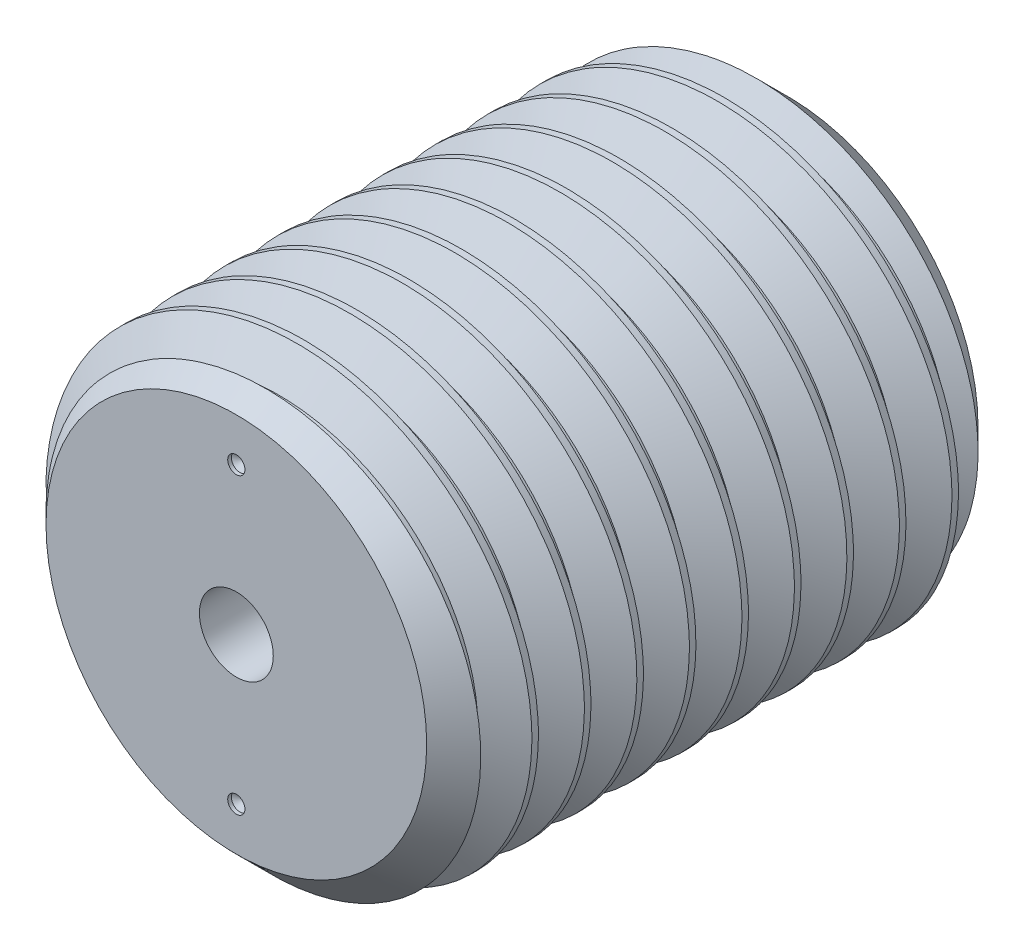
from build123d import *

# Parameters (mm, degrees)
SKETCH1_R                           = 15.875
BOSS_EXTRUDE1_DEPTH                 = 19.05
CHAMFER1_SIZE                       = 2.721428571
CUT_SWEEP1_PITCH                    = 3.628571429
CUT_SWEEP1_HEIGHT                   = 41.728571429
CUT_SWEEP1_RADIUS                   = 15.875
CUT_SWEEP1_START_ANGLE              = 90
F_1_4_20_TAPPED_HOLE1_D             = 5.1054
F_1_4_20_TAPPED_HOLE1_DEPTH         = 11.938
F_1_4_20_TAPPED_HOLE1_TIP           = 1.533816902
F_3_64_0_04688_DIAMETER_HOLE1_D     = 1.190752
F_3_64_0_04688_DIAMETER_HOLE1_DEPTH = 0.254
F_3_64_0_04688_DIAMETER_HOLE1_TIP   = 0.357737992


with BuildPart() as part:
    # Sketch1 → Boss-Extrude1 (new, symmetric)
    with BuildSketch(Plane.XY):
        with Locations(Location((0, 0, 0), (0, 0, 180))):
            Circle(SKETCH1_R)
    extrude(amount=BOSS_EXTRUDE1_DEPTH, both=True)

    # Chamfer1
    chamfer1_edges = [part.edges().sort_by_distance(p)[0] for p in [
        (15.875, 0, -19.05),
        (15.875, 0, 19.05),
    ]]
    chamfer(chamfer1_edges, length=CHAMFER1_SIZE)

    # Cut-Sweep1: sweep along a helix
    with BuildLine() as cut_sweep1_path:
        add(Helix(CUT_SWEEP1_PITCH, CUT_SWEEP1_HEIGHT, CUT_SWEEP1_RADIUS, center=(0, 0, 19.05), direction=(0, 0, -1), mode=Mode.PRIVATE).rotate(Axis((0, 0, 19.05), (0, 0, -1)), CUT_SWEEP1_START_ANGLE))
    # Sketch5 → Cut-Sweep1 (sweep, cut)
    with BuildSketch(Plane(origin=(0, 0, 0), x_dir=(0, 0, -1), z_dir=(1, 0, 0))):
        Polygon((-20.864285714, 13.518173723), (-20.410714286, 13.518173723), (-18.903353032, 16.129), (-22.371646968, 16.129), align=None)
    sweep(path=cut_sweep1_path.line, is_frenet=True, mode=Mode.SUBTRACT)

    # 1/4-20 Tapped Hole1
    with Locations(Plane.XY.offset(19.05)):
        with Locations((0, 0)):
            Hole(F_1_4_20_TAPPED_HOLE1_D / 2, depth=F_1_4_20_TAPPED_HOLE1_DEPTH)
            with Locations((0, 0, -(F_1_4_20_TAPPED_HOLE1_DEPTH + F_1_4_20_TAPPED_HOLE1_TIP / 2))):  # 118° drill point
                Cone(0, F_1_4_20_TAPPED_HOLE1_D / 2, F_1_4_20_TAPPED_HOLE1_TIP, mode=Mode.SUBTRACT)

    # 3/64 (0.04688) Diameter Hole1
    with Locations(Plane.XY.offset(19.05)):
        with Locations((0, 10.16), (0, -10.16)):
            Hole(F_3_64_0_04688_DIAMETER_HOLE1_D / 2, depth=F_3_64_0_04688_DIAMETER_HOLE1_DEPTH)
            with Locations((0, 0, -(F_3_64_0_04688_DIAMETER_HOLE1_DEPTH + F_3_64_0_04688_DIAMETER_HOLE1_TIP / 2))):  # 118° drill point
                Cone(0, F_3_64_0_04688_DIAMETER_HOLE1_D / 2, F_3_64_0_04688_DIAMETER_HOLE1_TIP, mode=Mode.SUBTRACT)


solid = part.part
